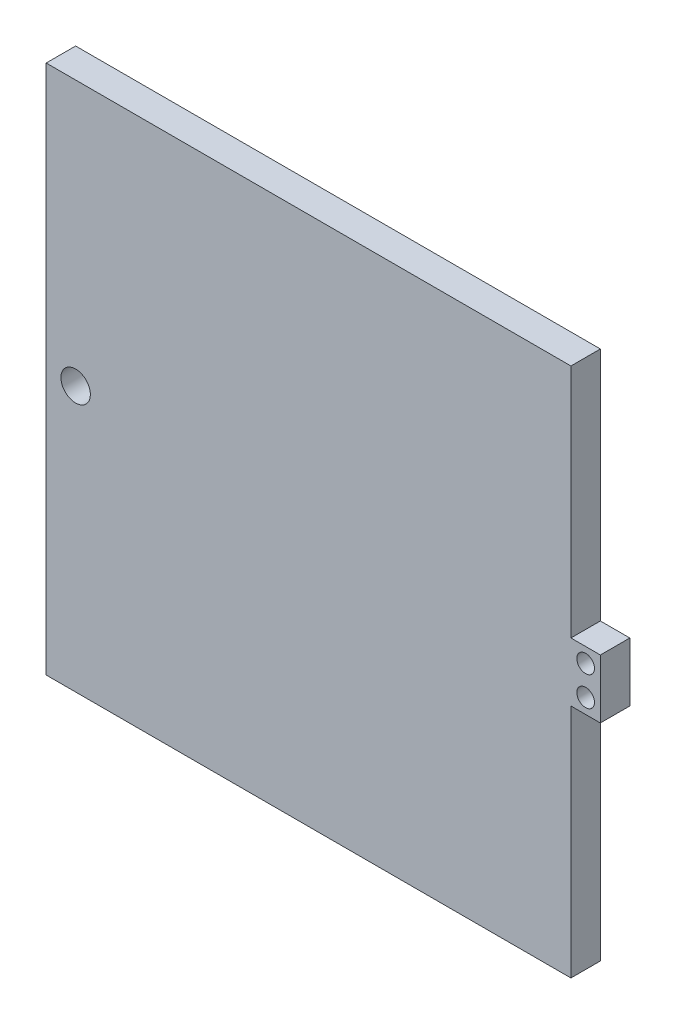
from build123d import *

# Parameters (mm, degrees)
SKETCH2_W           = 226.314
SKETCH2_H           = 215.9
BOSS_EXTRUDE1_DEPTH = 12.7
SKETCH3_W           = 12.7
SKETCH3_H           = 25.4
BOSS_EXTRUDE2_DEPTH = 12.7
SKETCH4_R           = 6.35
SKETCH4_R_2         = 3.81
CUT_EXTRUDE1_DEPTH  = 12.7
SKETCH5_W           = 226.314
SKETCH5_H           = 12.7
BOSS_EXTRUDE3_DEPTH = 12.7


with BuildPart() as part:
    # Sketch2 → Boss-Extrude1 (new body)
    with BuildSketch(Plane.XY):
        with Locations((-9.264561791, -20.772712934)):
            Rectangle(SKETCH2_W, SKETCH2_H)
    extrude(amount=BOSS_EXTRUDE1_DEPTH)

    # Sketch3 → Boss-Extrude2 (add)
    with BuildSketch(Plane(origin=(103.892438209, 0, 0), x_dir=(0, 0, -1), z_dir=(1, 0, 0))):
        with Locations((-6.35, -14.422712934)):
            Rectangle(SKETCH3_W, SKETCH3_H)
    extrude(amount=BOSS_EXTRUDE2_DEPTH)

    # Sketch4 → Cut-Extrude1 (cut)
    with BuildSketch(Plane(origin=(0, 0, 0), x_dir=(-1, 0, 0), z_dir=(0, 0, -1))):
        with Locations((109.721561791, -14.422712934)):
            Circle(SKETCH4_R)
        with Locations((-110.242438209, -8.072712934)):
            Circle(SKETCH4_R_2)
        with Locations((-110.242438209, -20.772712934)):
            Circle(SKETCH4_R_2)
    extrude(amount=-CUT_EXTRUDE1_DEPTH, mode=Mode.SUBTRACT)

    # Sketch5 → Boss-Extrude3 (add)
    with BuildSketch(Plane(origin=(0, 87.177287066, 0), x_dir=(1, 0, 0), z_dir=(0, 1, 0))):
        with Locations((-9.264561791, -6.35)):
            Rectangle(SKETCH5_W, SKETCH5_H)
    extrude(amount=BOSS_EXTRUDE3_DEPTH)


solid = part.part
